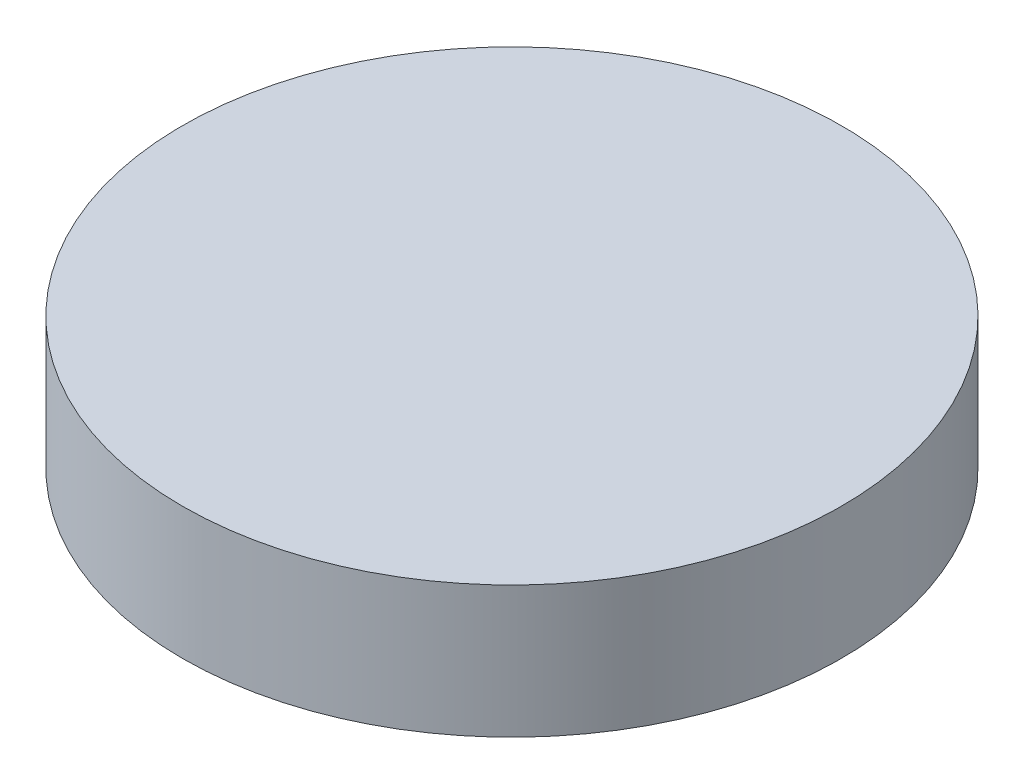
from build123d import *

# Parameters (mm, degrees)
SKETCH1_R           = 2.5
BOSS_EXTRUDE1_DEPTH = 1


with BuildPart() as part:
    # Sketch1 → Boss-Extrude1 (new body)
    with BuildSketch(Plane(origin=(0, 0, 0), x_dir=(1, 0, 0), z_dir=(0, 1, 0))):
        Circle(SKETCH1_R)
    extrude(amount=BOSS_EXTRUDE1_DEPTH)


solid = part.part
